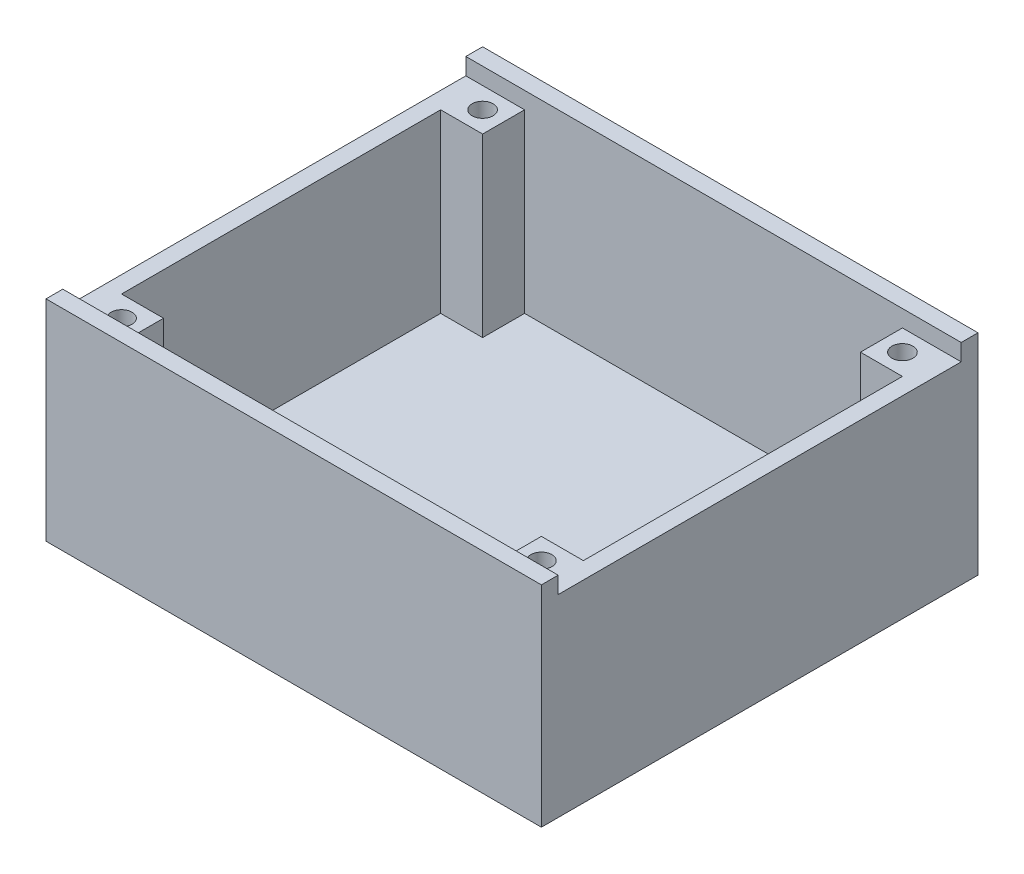
from build123d import *

# Parameters (mm, degrees)
SKETCH1_W               = 118
SKETCH1_H               = 104
SKETCH1_W_2             = 110
SKETCH1_H_2             = 96
BOSS_EXTRUDE1_DEPTH     = 50
SKETCH1_2_W             = 118
SKETCH1_2_H             = 104
BOSS_EXTRUDE2_DEPTH     = 4
SKETCH2_W               = 96
SKETCH2_H               = 4
CUT_EXTRUDE1_DEPTH      = 1
CUT_EXTRUDE1_DEPTH_BACK = 119
SKETCH3_W               = 10
SKETCH3_H               = 10
BOSS_EXTRUDE3_DEPTH     = 42
SKETCH4_R               = 2.5
CUT_EXTRUDE2_DEPTH      = 10


with BuildPart() as part:
    # Sketch1 → Boss-Extrude1 (new body)
    with BuildSketch(Plane(origin=(0, 0, 0), x_dir=(1, 0, 0), z_dir=(0, 1, 0))):
        Rectangle(SKETCH1_W, SKETCH1_H)
        Rectangle(SKETCH1_W_2, SKETCH1_H_2, mode=Mode.SUBTRACT)
    extrude(amount=BOSS_EXTRUDE1_DEPTH)

    # Sketch1_2 → Boss-Extrude2 (add)
    with BuildSketch(Plane(origin=(0, 0, 0), x_dir=(1, 0, 0), z_dir=(0, 1, 0))):
        Rectangle(SKETCH1_2_W, SKETCH1_2_H)
    extrude(amount=BOSS_EXTRUDE2_DEPTH)

    # Sketch2 → Cut-Extrude1 (cut, two sides)
    with BuildSketch(Plane(origin=(59, 0, 0), x_dir=(0, 0, -1), z_dir=(1, 0, 0))) as cut_extrude1_sk:
        with Locations((0, 48)):
            Rectangle(SKETCH2_W, SKETCH2_H)
    extrude(amount=CUT_EXTRUDE1_DEPTH, mode=Mode.SUBTRACT)
    extrude(cut_extrude1_sk.sketch, amount=-CUT_EXTRUDE1_DEPTH_BACK, mode=Mode.SUBTRACT)

    # Sketch3 → Boss-Extrude3 (add)
    with BuildSketch(Plane(origin=(0, 4, 0), x_dir=(1, 0, 0), z_dir=(0, 1, 0))):
        with Locations((-50, 43)):
            Rectangle(SKETCH3_W, SKETCH3_H)
        with Locations((-50, -43)):
            Rectangle(SKETCH3_W, SKETCH3_H)
        with Locations((50, -43)):
            Rectangle(SKETCH3_W, SKETCH3_H)
        with Locations((50, 43)):
            Rectangle(SKETCH3_W, SKETCH3_H)
    extrude(amount=BOSS_EXTRUDE3_DEPTH)

    # Sketch4 → Cut-Extrude2 (cut)
    with BuildSketch(Plane(origin=(0, 46, 0), x_dir=(1, 0, 0), z_dir=(0, 1, 0))):
        with Locations((-50, 43)):
            Circle(SKETCH4_R)
        with Locations((50, 43)):
            Circle(SKETCH4_R)
        with Locations((50, -43)):
            Circle(SKETCH4_R)
        with Locations((-50, -43)):
            Circle(SKETCH4_R)
    extrude(amount=-CUT_EXTRUDE2_DEPTH, mode=Mode.SUBTRACT)


solid = part.part
